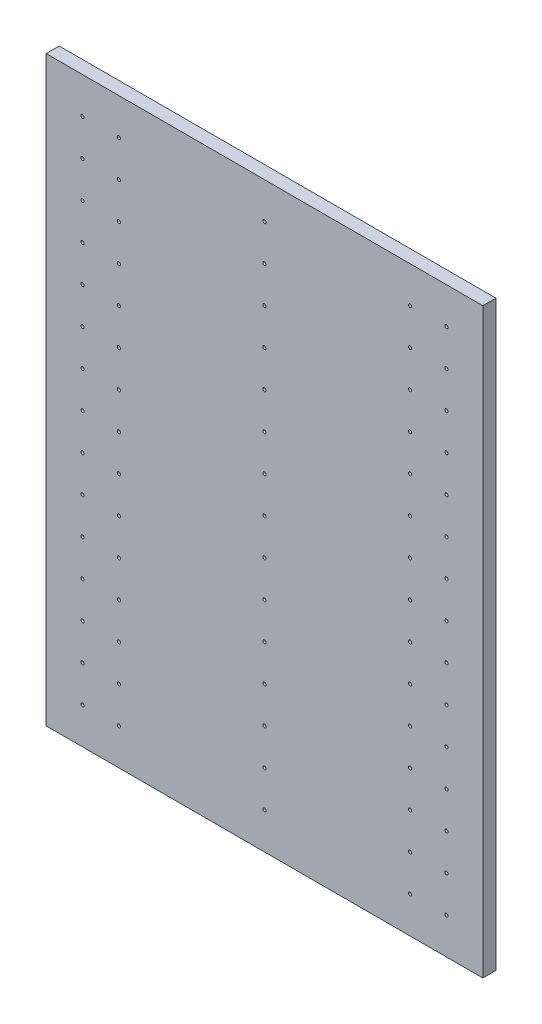
from build123d import *

# Parameters (mm, degrees)
SKETCH_1_W          = 600
SKETCH_1_H          = 800
EXTRUDE_1_DEPTH     = 18
SKETCH_2_R          = 2.25
CUT_EXTRUDE_1_DEPTH = 9


with BuildPart() as part:
    # Эскиз1 → Бобышка-Вытянуть1 (new body)
    with BuildSketch(Plane.XY):
        with Locations((300, 400)):
            Rectangle(SKETCH_1_W, SKETCH_1_H)
    extrude(amount=EXTRUDE_1_DEPTH)

    # Эскиз2 → Вырез-Вытянуть1 (cut)
    with BuildSketch(Plane.XY.offset(18)):
        with Locations((550, 50)):
            Circle(SKETCH_2_R)
        with Locations((500, 50)):
            Circle(SKETCH_2_R)
        with Locations((300, 50)):
            Circle(SKETCH_2_R)
        with Locations((100, 50)):
            Circle(SKETCH_2_R)
        with Locations((50, 50)):
            Circle(SKETCH_2_R)
        with Locations((550, 100)):
            Circle(SKETCH_2_R)
        with Locations((500, 100)):
            Circle(SKETCH_2_R)
        with Locations((300, 100)):
            Circle(SKETCH_2_R)
        with Locations((100, 100)):
            Circle(SKETCH_2_R)
        with Locations((50, 100)):
            Circle(SKETCH_2_R)
        with Locations((550, 150)):
            Circle(SKETCH_2_R)
        with Locations((500, 150)):
            Circle(SKETCH_2_R)
        with Locations((300, 150)):
            Circle(SKETCH_2_R)
        with Locations((100, 150)):
            Circle(SKETCH_2_R)
        with Locations((50, 150)):
            Circle(SKETCH_2_R)
        with Locations((550, 200)):
            Circle(SKETCH_2_R)
        with Locations((500, 200)):
            Circle(SKETCH_2_R)
        with Locations((300, 200)):
            Circle(SKETCH_2_R)
        with Locations((100, 200)):
            Circle(SKETCH_2_R)
        with Locations((50, 200)):
            Circle(SKETCH_2_R)
        with Locations((550, 250)):
            Circle(SKETCH_2_R)
        with Locations((500, 250)):
            Circle(SKETCH_2_R)
        with Locations((300, 250)):
            Circle(SKETCH_2_R)
        with Locations((100, 250)):
            Circle(SKETCH_2_R)
        with Locations((50, 250)):
            Circle(SKETCH_2_R)
        with Locations((550, 300)):
            Circle(SKETCH_2_R)
        with Locations((500, 300)):
            Circle(SKETCH_2_R)
        with Locations((300, 300)):
            Circle(SKETCH_2_R)
        with Locations((100, 300)):
            Circle(SKETCH_2_R)
        with Locations((50, 300)):
            Circle(SKETCH_2_R)
        with Locations((550, 350)):
            Circle(SKETCH_2_R)
        with Locations((500, 350)):
            Circle(SKETCH_2_R)
        with Locations((300, 350)):
            Circle(SKETCH_2_R)
        with Locations((100, 350)):
            Circle(SKETCH_2_R)
        with Locations((50, 350)):
            Circle(SKETCH_2_R)
        with Locations((550, 400)):
            Circle(SKETCH_2_R)
        with Locations((500, 400)):
            Circle(SKETCH_2_R)
        with Locations((300, 400)):
            Circle(SKETCH_2_R)
        with Locations((100, 400)):
            Circle(SKETCH_2_R)
        with Locations((50, 400)):
            Circle(SKETCH_2_R)
        with Locations((550, 450)):
            Circle(SKETCH_2_R)
        with Locations((500, 450)):
            Circle(SKETCH_2_R)
        with Locations((300, 450)):
            Circle(SKETCH_2_R)
        with Locations((100, 450)):
            Circle(SKETCH_2_R)
        with Locations((50, 450)):
            Circle(SKETCH_2_R)
        with Locations((550, 500)):
            Circle(SKETCH_2_R)
        with Locations((500, 500)):
            Circle(SKETCH_2_R)
        with Locations((300, 500)):
            Circle(SKETCH_2_R)
        with Locations((100, 500)):
            Circle(SKETCH_2_R)
        with Locations((50, 500)):
            Circle(SKETCH_2_R)
        with Locations((550, 550)):
            Circle(SKETCH_2_R)
        with Locations((500, 550)):
            Circle(SKETCH_2_R)
        with Locations((300, 550)):
            Circle(SKETCH_2_R)
        with Locations((100, 550)):
            Circle(SKETCH_2_R)
        with Locations((50, 550)):
            Circle(SKETCH_2_R)
        with Locations((550, 600)):
            Circle(SKETCH_2_R)
        with Locations((500, 600)):
            Circle(SKETCH_2_R)
        with Locations((300, 600)):
            Circle(SKETCH_2_R)
        with Locations((100, 600)):
            Circle(SKETCH_2_R)
        with Locations((50, 600)):
            Circle(SKETCH_2_R)
        with Locations((550, 650)):
            Circle(SKETCH_2_R)
        with Locations((500, 650)):
            Circle(SKETCH_2_R)
        with Locations((300, 650)):
            Circle(SKETCH_2_R)
        with Locations((100, 650)):
            Circle(SKETCH_2_R)
        with Locations((50, 650)):
            Circle(SKETCH_2_R)
        with Locations((550, 700)):
            Circle(SKETCH_2_R)
        with Locations((500, 700)):
            Circle(SKETCH_2_R)
        with Locations((300, 700)):
            Circle(SKETCH_2_R)
        with Locations((100, 700)):
            Circle(SKETCH_2_R)
        with Locations((50, 700)):
            Circle(SKETCH_2_R)
        with Locations((550, 750)):
            Circle(SKETCH_2_R)
        with Locations((500, 750)):
            Circle(SKETCH_2_R)
        with Locations((300, 750)):
            Circle(SKETCH_2_R)
        with Locations((100, 750)):
            Circle(SKETCH_2_R)
        with Locations((50, 750)):
            Circle(SKETCH_2_R)
    extrude(amount=-CUT_EXTRUDE_1_DEPTH, mode=Mode.SUBTRACT)


solid = part.part
